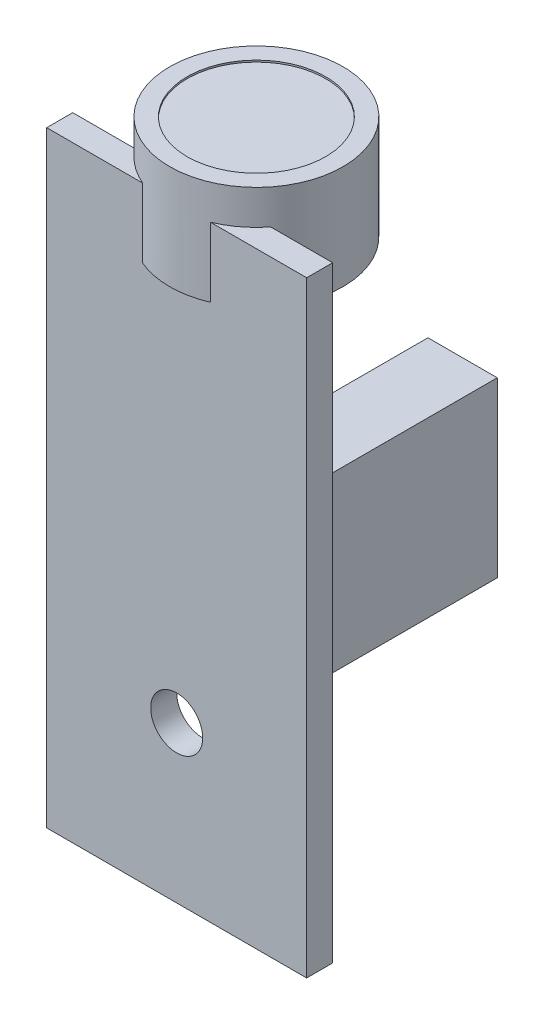
from build123d import *

# Parameters (mm, degrees)
SKETCH1_W                = 15
SKETCH1_H                = 35
SKETCH1_R                = 1.5
BOSS_EXTRUDE1_DEPTH      = 1.5
SKETCH2_R                = 5
BOSS_EXTRUDE2_DEPTH      = 2
BOSS_EXTRUDE2_DEPTH_BACK = 4
SKETCH3_R                = 4
CUT_EXTRUDE1_DEPTH       = 0.1
SKETCH4_W                = 4
SKETCH4_H                = 10
BOSS_EXTRUDE3_DEPTH      = 10


with BuildPart() as part:
    # Sketch1 → Boss-Extrude1 (new body)
    with BuildSketch(Plane.XY):
        with Locations((220.135234982, 151.894136477)):
            Rectangle(SKETCH1_W, SKETCH1_H)
        with Locations((220.135234982, 143.394136477)):
            Circle(SKETCH1_R, mode=Mode.SUBTRACT)
    extrude(amount=BOSS_EXTRUDE1_DEPTH)

    # Sketch2 → Boss-Extrude2 (add, two sides)
    with BuildSketch(Plane(origin=(0, 169.394136477, 0), x_dir=(1, 0, 0), z_dir=(0, 1, 0))) as boss_extrude2_sk:
        with Locations((220.135234982, 3.1)):
            Circle(SKETCH2_R)
    extrude(amount=BOSS_EXTRUDE2_DEPTH)
    extrude(boss_extrude2_sk.sketch, amount=-BOSS_EXTRUDE2_DEPTH_BACK)

    # Sketch3 → Cut-Extrude1 (cut)
    with BuildSketch(Plane(origin=(0, 171.394136477, 0), x_dir=(1, 0, 0), z_dir=(0, 1, 0))):
        with Locations((220.135234982, 3.1)):
            Circle(SKETCH3_R)
    extrude(amount=-CUT_EXTRUDE1_DEPTH, mode=Mode.SUBTRACT)

    # Sketch4 → Boss-Extrude3 (add)
    with BuildSketch(Plane(origin=(0, 0, 0), x_dir=(-1, 0, 0), z_dir=(0, 0, -1))):
        with Locations((-225.135234982, 153.394136477)):
            Rectangle(SKETCH4_W, SKETCH4_H)
    extrude(amount=BOSS_EXTRUDE3_DEPTH)


solid = part.part
